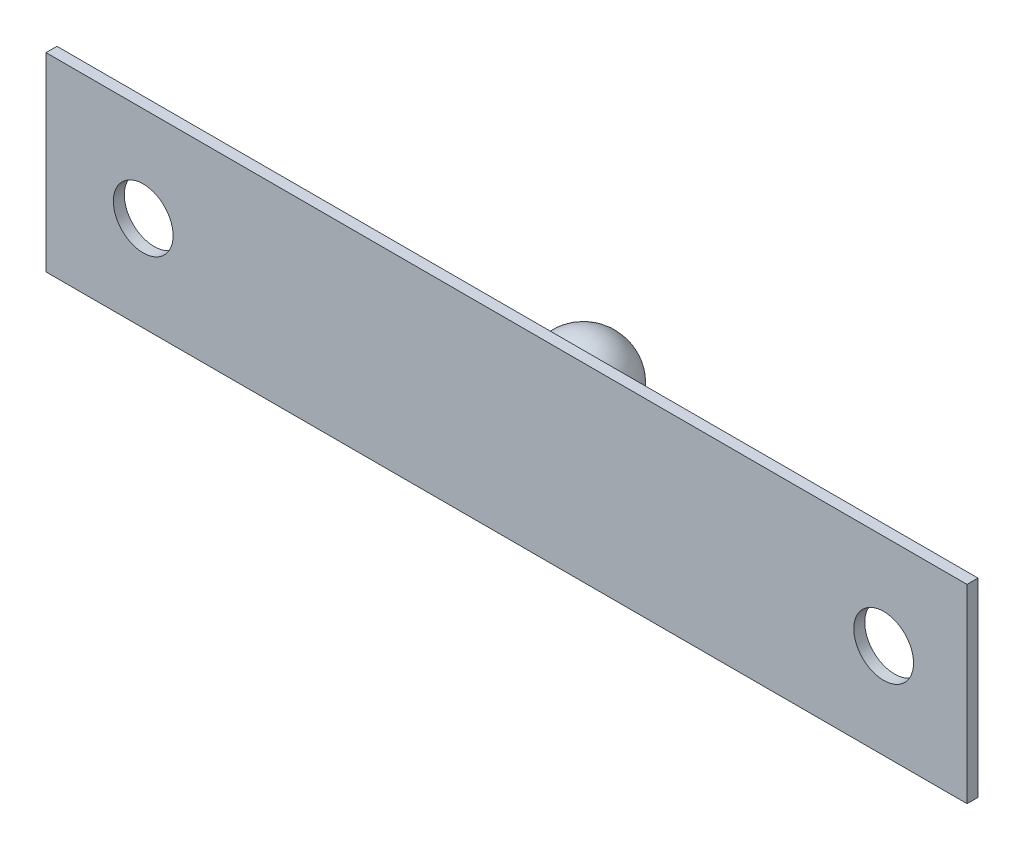
from build123d import *

# Parameters (mm, degrees)
SKETCH1_W           = 37
SKETCH1_H           = 7.63
SKETCH1_R           = 1.2
BOSS_EXTRUDE1_DEPTH = 0.44


with BuildPart() as part:
    # Sketch1 → Boss-Extrude1 (new body)
    with BuildSketch(Plane.XY):
        Rectangle(SKETCH1_W, SKETCH1_H)
        with Locations((-14.59410802, 0)):
            Circle(SKETCH1_R, mode=Mode.SUBTRACT)
        with Locations((15.15, 0)):
            Circle(SKETCH1_R, mode=Mode.SUBTRACT)
    extrude(amount=BOSS_EXTRUDE1_DEPTH)

    # Sketch2 → Revolve2 (revolve)
    with BuildSketch(Plane(origin=(0, 0, 0), x_dir=(1, 0, 0), z_dir=(0, 1, 0))):
        with BuildLine():
            Line((0, 0), (0, 4.42))
            ThreePointArc((0, 4.42), (-1.543186446, 3.522040816), (-1.525, 1.736704894))
            Line((-1.525, 1.736704894), (-1.525, 0))
            Line((-1.525, 0), (0, 0))
        make_face()
    revolve(axis=Axis((0, 0, 0), (0, 0, -1)))


solid = part.part
